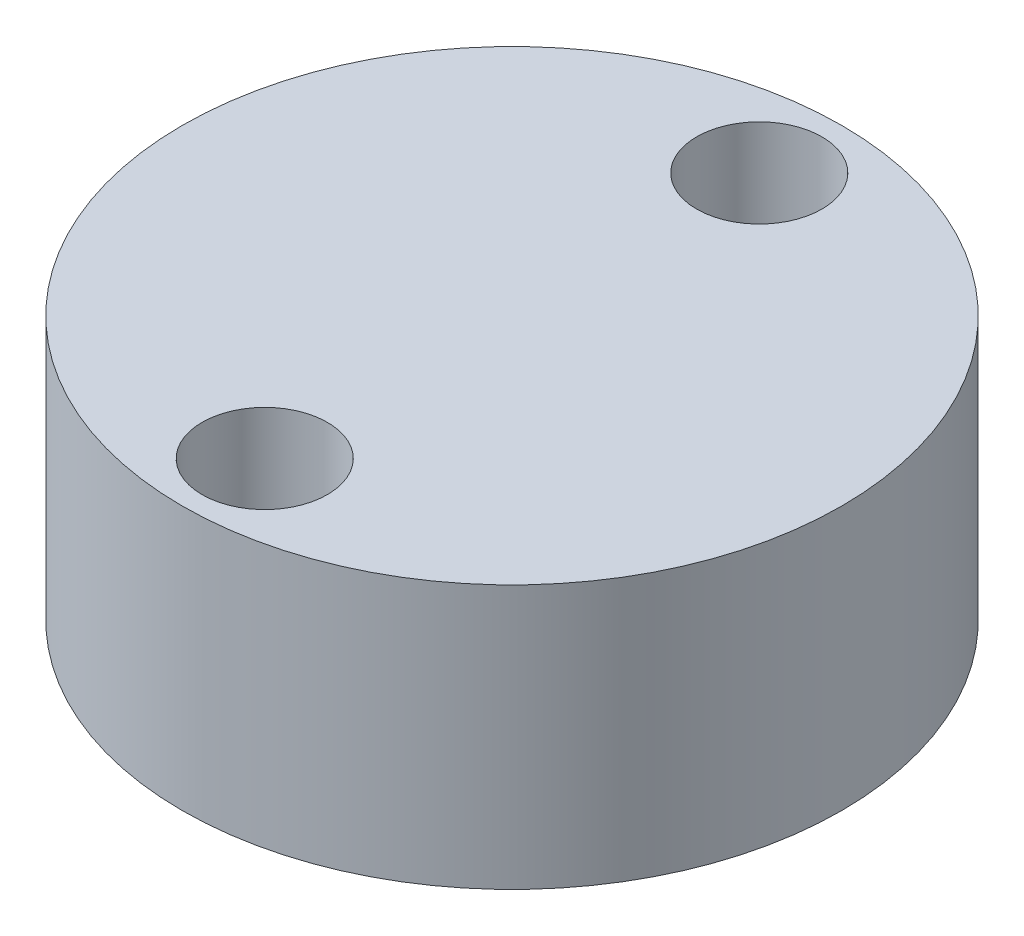
from build123d import *

# Parameters (mm, degrees)
SKETCH1_R           = 5
SKETCH1_R_2         = 0.5
BOSS_EXTRUDE1_DEPTH = 4
SKETCH2_R           = 0.95
CUT_EXTRUDE1_DEPTH  = 2


with BuildPart() as part:
    # Sketch1 → Boss-Extrude1 (new body)
    with BuildSketch(Plane(origin=(0, 0, 0), x_dir=(1, 0, 0), z_dir=(0, 1, 0))):
        Circle(SKETCH1_R)
        with Locations((0, 3.75)):
            Circle(SKETCH1_R_2, mode=Mode.SUBTRACT)
        with Locations((0, -3.75)):
            Circle(SKETCH1_R_2, mode=Mode.SUBTRACT)
    extrude(amount=BOSS_EXTRUDE1_DEPTH)

    # Sketch2 → Cut-Extrude1 (cut)
    with BuildSketch(Plane(origin=(0, 4, 0), x_dir=(1, 0, 0), z_dir=(0, 1, 0))):
        with Locations((0, 3.75)):
            Circle(SKETCH2_R)
        with Locations((0, -3.75)):
            Circle(SKETCH2_R)
    extrude(amount=-CUT_EXTRUDE1_DEPTH, mode=Mode.SUBTRACT)


solid = part.part
